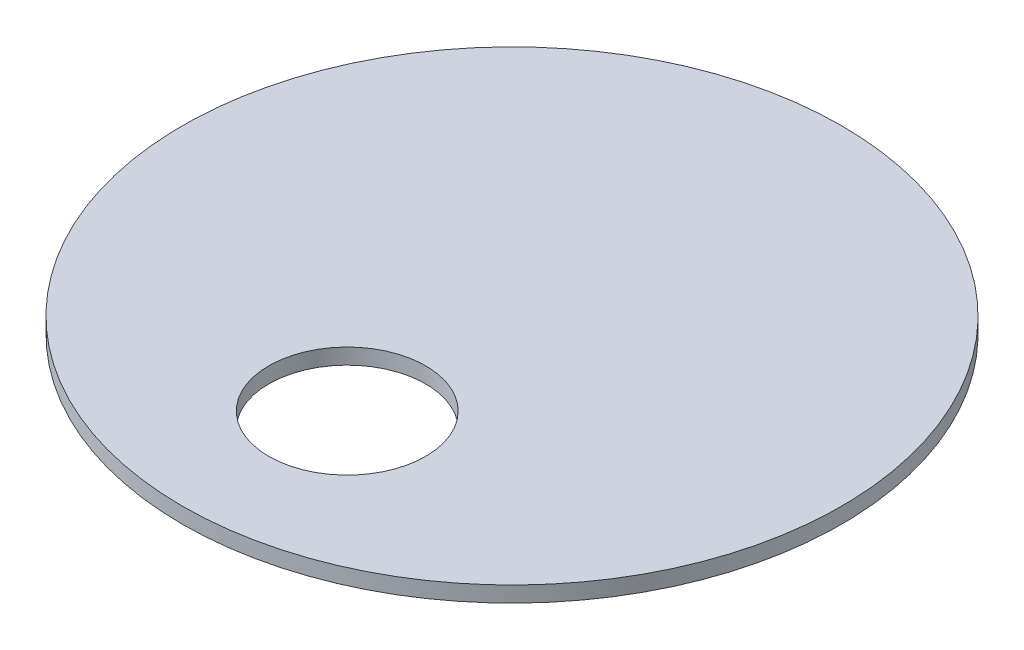
from build123d import *

# Parameters (mm, degrees)
SKETCH1_R           = 105
SKETCH1_R_2         = 25
BOSS_EXTRUDE4_DEPTH = 5


with BuildPart() as part:
    # Sketch1 → Boss-Extrude4 (new body)
    with BuildSketch(Plane(origin=(0, 0, 0), x_dir=(1, 0, 0), z_dir=(0, 1, 0))):
        Circle(SKETCH1_R)
        with Locations((0, -52.5)):
            Circle(SKETCH1_R_2, mode=Mode.SUBTRACT)
    extrude(amount=BOSS_EXTRUDE4_DEPTH)


solid = part.part
